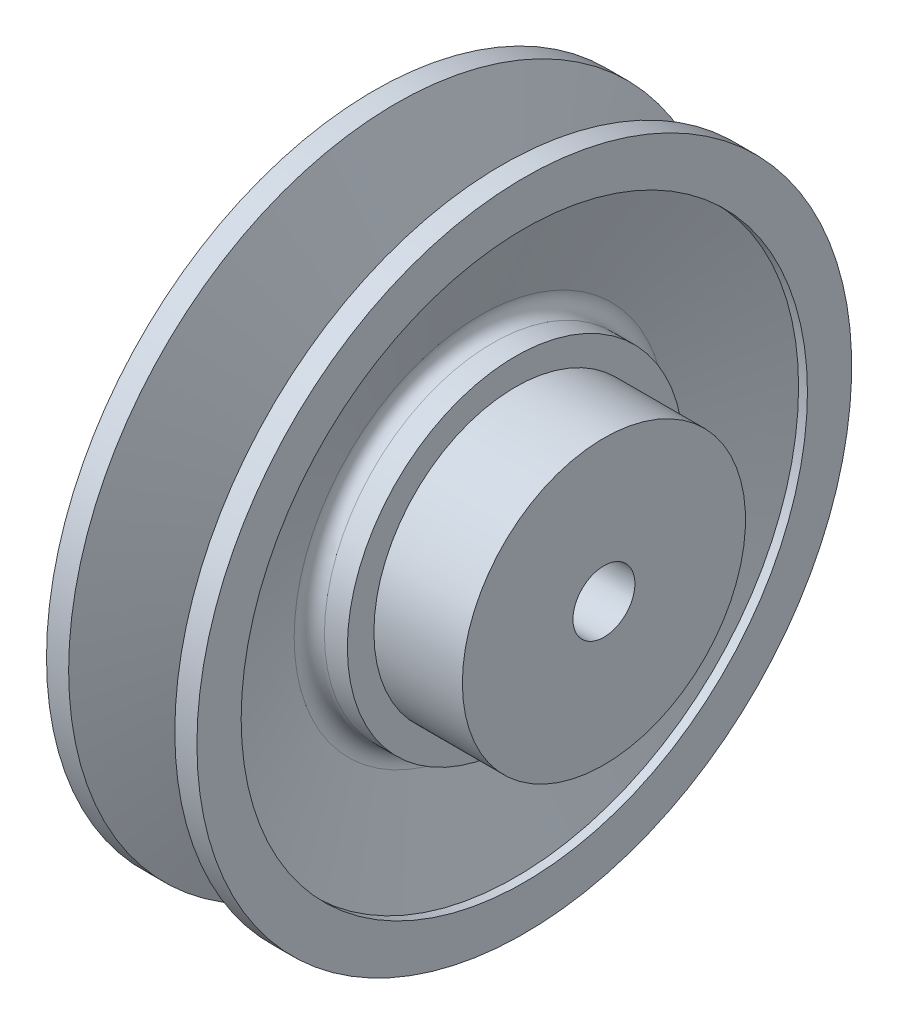
from build123d import *

# Parameters (mm, degrees)
FILLET2_R = 3


with BuildPart() as part:
    # Sketch1 → Revolve1 (revolve)
    with BuildSketch(Plane.XY):
        Polygon((-36.251976392, 8.148460305), (13.748023608, 8.148460305), (13.748023608, 33.148460305), (-6.251976392, 33.148460305), (-6.251976392, 39.148460305), (-15.715202483, 39.148460305), (-6.251976392, 65.148460305), (-4.251976392, 65.148460305), (-4.251976392, 75.148460305), (-9.251976392, 75.148460305), (-18.351232248, 50.148460305), (-24.152720535, 50.148460305), (-33.251976392, 75.148460305), (-38.251976392, 75.148460305), (-38.251976392, 65.148460305), (-36.251976392, 65.148460305), (-26.788750301, 39.148460305), (-36.251976392, 39.148460305), align=None)
    revolve(axis=Axis((-66.203541658, 1.148460305, 0), (1, 0, 0)))

    # Fillet2
    fillet2_edges = [part.edges().sort_by_distance(p)[0] for p in [
        (-26.788750301, -36.851539695, 0),
        (-24.152720535, -47.851539695, 0),
        (-18.351232248, -47.851539695, 0),
        (-15.715202483, -36.851539695, 0),
    ]]
    fillet(fillet2_edges, radius=FILLET2_R)


solid = part.part
